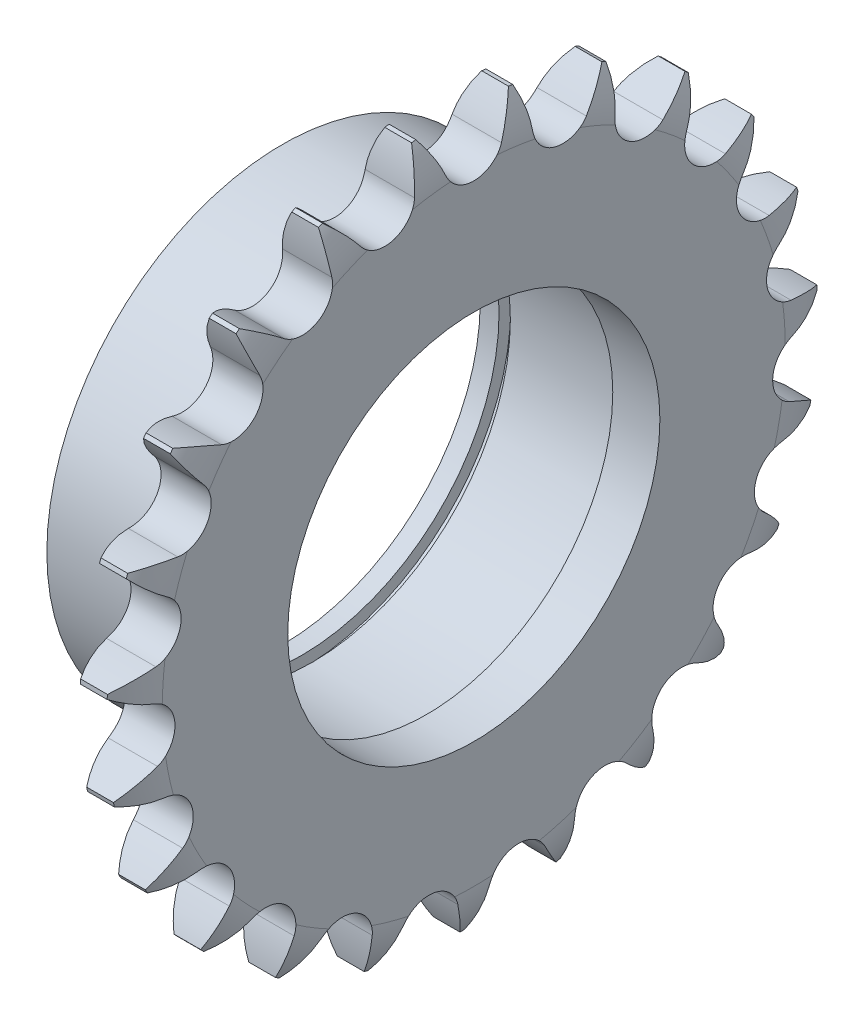
from build123d import *

# Parameters (mm, degrees)
TOOTHCUT_DEPTH      = 6.3196
TEETHCUTS_COUNT     = 23
TEETHCUTS_ANGLE     = 344.347826087
HUBNEAONESKE_R      = 25
HUBNEARONE_DEPTH    = 15
HUBNEARONEFILLET_R  = 0.4
BORSKE_R            = 21
BORE_DEPTH          = 17.0005
SKETCH2_R           = 21
SKETCH2_R_2         = 19.75
BOSS_EXTRUDE1_DEPTH = 5
SKETCH4_R           = 22.25
SKETCH4_R_2         = 21
CUT_EXTRUDE1_DEPTH  = 3.2
SKETCH5_R           = 22.25
SKETCH5_R_2         = 21
BOSS_EXTRUDE2_DEPTH = 2


with BuildPart() as part:
    # BasProSke → Base-Revolve (revolve)
    with BuildSketch(Plane(origin=(0, 0, 0), x_dir=(1, 0, 0), z_dir=(0, 1, 0))):
        with BuildLine():
            Line((0, 0), (0, 33.05777326))
            ThreePointArc((0, 33.05777326), (0.314698702, 35.485936145), (1.238, 37.753649749))
            Line((1.238, 37.753649749), (4.0816, 37.753649749))
            ThreePointArc((4.0816, 37.753649749), (5.004901298, 35.485936145), (5.3196, 33.05777326))
            Line((5.3196, 33.05777326), (5.3196, 0))
            Line((5.3196, 0), (0, 0))
        make_face()
    revolve(axis=Axis((-10, 0, 0), (1, 0, 0)))

    # TooCutSke → ToothCut (cut, through all)
    with BuildSketch(Plane(origin=(0, 0, 0), x_dir=(0, 0, -1), z_dir=(1, 0, 0))):
        with BuildLine():
            ThreePointArc((2.97415754, 33.808261616), (3.980578959, 35.920428815), (5.23833278, 37.893292134))
            ThreePointArc((5.23833278, 37.893292134), (0, 38.253649749), (-5.23833278, 37.893292134))
            ThreePointArc((-5.23833278, 37.893292134), (-3.980578959, 35.920428815), (-2.97415754, 33.808261616))
            ThreePointArc((-2.97415754, 33.808261616), (0, 31.800524749), (2.97415754, 33.808261616))
        make_face()
    toothcut = extrude(amount=TOOTHCUT_DEPTH, mode=Mode.SUBTRACT)

    # TeethCuts: ToothCut ×23 about axis
    teethcuts_axis = Axis((-10, 0, 0), (1, 0, 0))
    for i in range(1, TEETHCUTS_COUNT):
        add(toothcut.rotate(teethcuts_axis, i * TEETHCUTS_ANGLE / (TEETHCUTS_COUNT - 1)), mode=Mode.SUBTRACT)

    # HubNeaOneSke → HubNearOne (add)
    with BuildSketch(Plane.ZY):
        Circle(HUBNEAONESKE_R)
    extrude(amount=HUBNEARONE_DEPTH)

    # HubNearOneFillet
    hubnearonefillet_edges = [part.edges().sort_by_distance(p)[0] for p in [
        (0, 0, -25),
    ]]
    fillet(hubnearonefillet_edges, radius=HUBNEARONEFILLET_R)

    # BorSke → Bore (cut, symmetric)
    with BuildSketch(Plane(origin=(0, 0, 0), x_dir=(0, 0, -1), z_dir=(1, 0, 0))):
        Circle(BORSKE_R)
    extrude(amount=BORE_DEPTH, both=True, mode=Mode.SUBTRACT)

    # Sketch2 → Boss-Extrude1 (add)
    with BuildSketch(Plane(origin=(5.3196, 0, 0), x_dir=(0, 0, -1), z_dir=(1, 0, 0))):
        Circle(SKETCH2_R)
        Circle(SKETCH2_R_2, mode=Mode.SUBTRACT)
    extrude(amount=-BOSS_EXTRUDE1_DEPTH)

    # Sketch4 → Cut-Extrude1 (cut)
    with BuildSketch(Plane.ZY.offset(15)):
        Circle(SKETCH4_R)
        Circle(SKETCH4_R_2, mode=Mode.SUBTRACT)
    extrude(amount=-CUT_EXTRUDE1_DEPTH, mode=Mode.SUBTRACT)

    # Sketch5 → Boss-Extrude2 (add)
    with BuildSketch(Plane.ZY.offset(15)):
        Circle(SKETCH5_R)
        Circle(SKETCH5_R_2, mode=Mode.SUBTRACT)
    extrude(amount=-BOSS_EXTRUDE2_DEPTH)


solid = part.part
